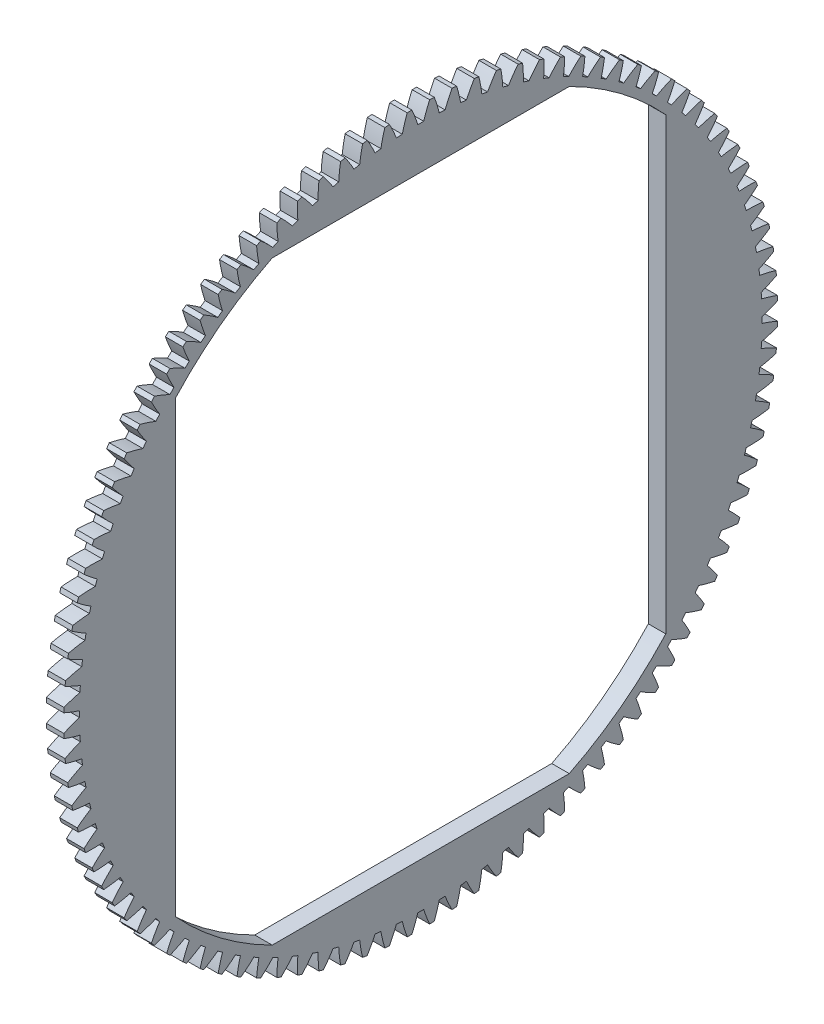
from build123d import *

# Parameters (mm, degrees)
BASPROSKE_W        = 6.35
BASPROSKE_H        = 129.54
TOOTHCUT_DEPTH     = 184.307243992
TEETHCUTS_COUNT    = 100
TEETHCUTS_ANGLE    = 356.4
BORSKE_R           = 0.396875
BORE_DEPTH         = 50.8000508
CUT_EXTRUDE1_DEPTH = 184.250318875


with BuildPart() as part:
    # BasProSke → Base-Revolve (revolve)
    with BuildSketch(Plane(origin=(0, 0, 0), x_dir=(1, 0, 0), z_dir=(0, 1, 0)), mode=Mode.PRIVATE) as base_revolve_sk:
        with Locations((3.175, 64.77)):
            Rectangle(BASPROSKE_W, BASPROSKE_H)
    revolve(base_revolve_sk.sketch.rotate(Axis((-10, 0, 0), (1, 0, 0)), 180), axis=Axis((-10, 0, 0), (1, 0, 0)))

    # TooCutSke → ToothCut (cut, through all)
    with BuildSketch(Plane(origin=(0, 0, 0), x_dir=(0, 0, -1), z_dir=(1, 0, 0))):
        with BuildLine():
            ThreePointArc((1.062355509, 123.819172634), (0, 123.82373), (-1.062355509, 123.819172634))
            ThreePointArc((-1.062355509, 123.819172634), (-2.066053248, 126.704787825), (-3.241402629, 129.524847756))
            ThreePointArc((-3.241402629, 129.524847756), (0, 129.5654), (3.241402629, 129.524847756))
            ThreePointArc((3.241402629, 129.524847756), (2.066053248, 126.704787825), (1.062355509, 123.819172634))
        make_face()
    toothcut = extrude(amount=TOOTHCUT_DEPTH, mode=Mode.SUBTRACT)

    # TeethCuts: ToothCut ×100 about axis
    teethcuts_axis = Axis((-10, 0, 0), (1, 0, 0))
    for i in range(1, TEETHCUTS_COUNT):
        add(toothcut.rotate(teethcuts_axis, i * TEETHCUTS_ANGLE / (TEETHCUTS_COUNT - 1)), mode=Mode.SUBTRACT)

    # BorSke → Bore (cut, symmetric)
    with BuildSketch(Plane(origin=(0, 0, 0), x_dir=(0, 0, -1), z_dir=(1, 0, 0))):
        with Locations(Location((0, 0, 0), (0, 0, 180))):
            Circle(BORSKE_R)
    extrude(amount=BORE_DEPTH, both=True, mode=Mode.SUBTRACT)

    # Sketch2 → Cut-Extrude1 (cut, through all)
    with BuildSketch(Plane(origin=(6.35, 0, 0), x_dir=(0, 0, -1), z_dir=(1, 0, 0))):
        with BuildLine():
            Line((88.9, -81.170351875), (88.9, 81.964101875))
            ThreePointArc((88.9, 81.964101875), (72.599273322, 96.759564943), (53.881536726, 108.346875))
            Line((53.881536726, 108.346875), (-53.881536726, 108.346875))
            ThreePointArc((-53.881536726, 108.346875), (-72.599273322, 96.759564943), (-88.9, 81.964101875))
            Line((-88.9, 81.964101875), (-88.9, -81.170351875))
            ThreePointArc((-88.9, -81.170351875), (-72.599273322, -95.965814943), (-53.881536726, -107.553125))
            Line((-53.881536726, -107.553125), (53.881536726, -107.553125))
            ThreePointArc((53.881536726, -107.553125), (72.599273322, -95.965814943), (88.9, -81.170351875))
        make_face()
    extrude(amount=-CUT_EXTRUDE1_DEPTH, mode=Mode.SUBTRACT)


solid = part.part
